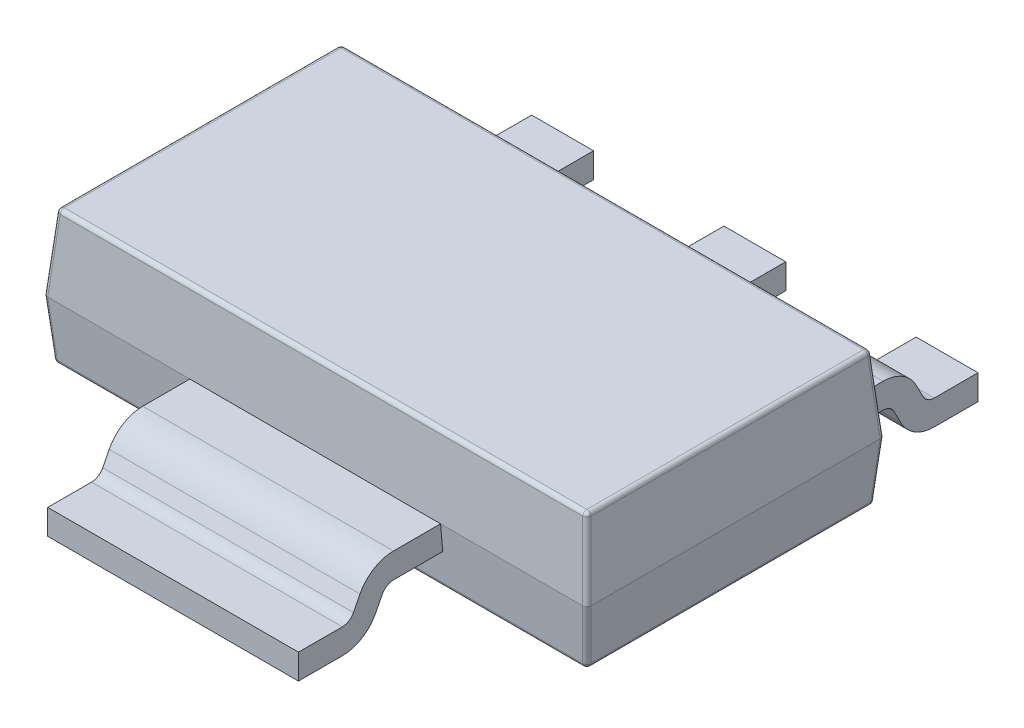
from build123d import *

# Parameters (mm, degrees)
SKETCH1_W                = 6.5
SKETCH1_H                = 3.56
EXTRUDE1_DEPTH           = 0.9
EXTRUDE1_TAPER           = 5
EXTRUDE1_OTHER_WAY_DEPTH = 0.7
EXTRUDE1_OTHER_WAY_TAPER = 5
EXTRUDE2_DEPTH           = 0.37
LPATTERN1_COUNT          = 2
LPATTERN1_PITCH          = 2.3
LPATTERN1_COL_COUNT      = 2
LPATTERN1_COL_PITCH      = 2.3
EXTRUDE3_DEPTH           = 1.5
EXTRUDE3_DEPTH_BACK      = 1.5
FILLET2_R                = 0.45
FILLET1_R                = 0.15
FILLET3_R                = 0.05


with BuildPart() as part:
    # Sketch1 → Extrude1 (new body)
    with BuildSketch(Plane(origin=(0, 0, 0), x_dir=(1, 0, 0), z_dir=(0, 1, 0))):
        Rectangle(SKETCH1_W, SKETCH1_H)
    extrude(amount=EXTRUDE1_DEPTH, taper=EXTRUDE1_TAPER)

    # Sketch1 → Extrude1 other way (add)
    with BuildSketch(Plane(origin=(0, 0, 0), x_dir=(1, 0, 0), z_dir=(0, 1, 0))):
        Rectangle(SKETCH1_W, SKETCH1_H)
    extrude(amount=-EXTRUDE1_OTHER_WAY_DEPTH, taper=EXTRUDE1_OTHER_WAY_TAPER)

    # Sketch2 → Extrude2 (add, symmetric)
    with BuildSketch(Plane(origin=(0, 0, 0), x_dir=(0, 0, -1), z_dir=(1, 0, 0))):
        Polygon((1.78, -0.3), (1.580889401, -0.3), (1.78, 0), (2.619268021, 0), (2.863840236, -0.48), (3.48, -0.48), (3.48, -0.78), (2.68, -0.78), (2.435427784, -0.3), align=None)
    extrude2 = extrude(amount=EXTRUDE2_DEPTH, both=True)

    # LPattern1: Extrude2 ×2
    with Locations(*[(-i * LPATTERN1_PITCH, 0, 0) for i in range(1, LPATTERN1_COUNT)]):
        add(extrude2)

    # LPattern1 col: Extrude2 ×2
    with Locations(*[(i * LPATTERN1_COL_PITCH, 0, 0) for i in range(1, LPATTERN1_COL_COUNT)]):
        add(extrude2)

    # Sketch2_3 → Extrude3 (add, two sides)
    with BuildSketch(Plane(origin=(0, 0, 0), x_dir=(0, 0, -1), z_dir=(1, 0, 0))) as extrude3_sk:
        Polygon((-2.68, -0.78), (-3.48, -0.78), (-3.48, -0.48), (-2.863840236, -0.48), (-2.619268021, 0), (-1.78, 0), (-1.580889401, -0.3), (-1.78, -0.3), (-2.435427784, -0.3), align=None)
    extrude(amount=EXTRUDE3_DEPTH)
    extrude(extrude3_sk.sketch, amount=-EXTRUDE3_DEPTH_BACK)

    # Fillet2
    fillet2_edges = [part.edges().sort_by_distance(p)[0] for p in [
        (0, -0.78, 2.68),
        (0, 0, 2.619268021),
        (0, -0.78, -2.68),
        (0, 0, -2.619268021),
        (2.3, -0.78, -2.68),
        (2.3, 0, -2.619268021),
        (-2.3, -0.78, -2.68),
        (-2.3, 0, -2.619268021),
    ]]
    fillet(fillet2_edges, radius=FILLET2_R)

    # Fillet1
    fillet1_edges = [part.edges().sort_by_distance(p)[0] for p in [
        (0, -0.3, 2.435427784),
        (0, -0.48, 2.863840236),
        (0, -0.3, -2.435427784),
        (0, -0.48, -2.863840236),
        (2.3, -0.3, -2.435427784),
        (2.3, -0.48, -2.863840236),
        (-2.3, -0.3, -2.435427784),
        (-2.3, -0.48, -2.863840236),
    ]]
    fillet(fillet1_edges, radius=FILLET1_R)

    # Fillet3
    fillet3_edges = [part.edges().sort_by_distance(p)[0] for p in [
        (3.171260203, 0.9, 0),
        (-3.188757936, -0.7, 0),
        (-3.219378968, -0.35, 1.749378968),
        (0, -0.7, -1.718757936),
        (0, 0.9, -1.701260203),
        (-3.219378968, -0.35, -1.749378968),
        (3.188757936, -0.7, 0),
        (3.219378968, -0.35, -1.749378968),
        (0, -0.7, 1.718757936),
        (3.219378968, -0.35, 1.749378968),
        (-3.171260203, 0.9, 0),
        (0, 0.9, 1.701260203),
        (-3.210630101, 0.45, -1.740630101),
        (3.210630101, 0.45, -1.740630101),
        (3.210630101, 0.45, 1.740630101),
        (-3.210630101, 0.45, 1.740630101),
    ]]
    fillet(fillet3_edges, radius=FILLET3_R)


solid = part.part
